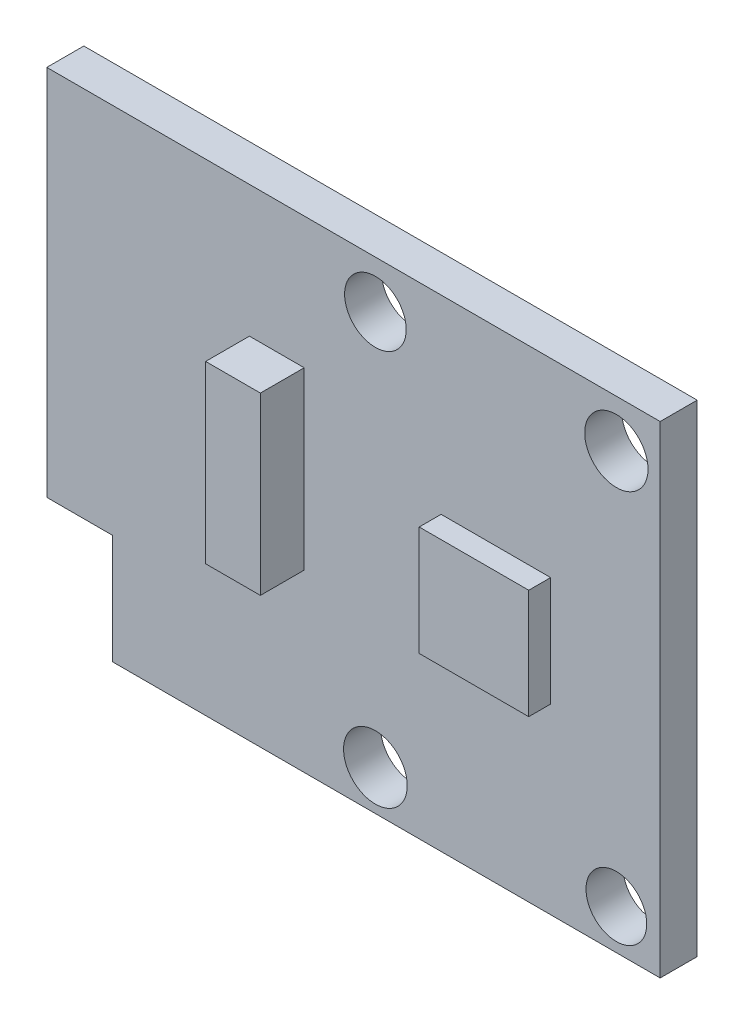
from build123d import *

# Parameters (mm, degrees)
SKETCH1_W           = 28
SKETCH1_H           = 22
BOSS_EXTRUDE1_DEPTH = 1.69
SKETCH2_R           = 1.445350302
SKETCH2_R_2         = 1.385905996
SKETCH2_R_3         = 1.453223353
SKETCH2_R_4         = 1.406338145
CUT_EXTRUDE1_DEPTH  = 1.69
SKETCH3_W           = 5
SKETCH3_H           = 5
BOSS_EXTRUDE2_DEPTH = 1
SKETCH4_W           = 2.5
SKETCH4_H           = 8
BOSS_EXTRUDE3_DEPTH = 2
SKETCH5_W           = 3
SKETCH5_H           = 5
CUT_EXTRUDE2_DEPTH  = 10


with BuildPart() as part:
    # Sketch1 → Boss-Extrude1 (new body)
    with BuildSketch(Plane.XY):
        with Locations((14, 11)):
            Rectangle(SKETCH1_W, SKETCH1_H)
    extrude(amount=BOSS_EXTRUDE1_DEPTH)

    # Sketch2 → Cut-Extrude1 (cut)
    with BuildSketch(Plane.XY.offset(1.69)):
        with Locations((26, 19.834515058)):
            Circle(SKETCH2_R)
        with Locations((26, 1.826288901)):
            Circle(SKETCH2_R_2)
        with Locations((15, 1.826288901)):
            Circle(SKETCH2_R_3)
        with Locations((15, 19.834515058)):
            Circle(SKETCH2_R_4)
    extrude(amount=-CUT_EXTRUDE1_DEPTH, mode=Mode.SUBTRACT)

    # Sketch3 → Boss-Extrude2 (add)
    with BuildSketch(Plane.XY.offset(1.69)):
        with Locations((20.5, 10.83040198)):
            Rectangle(SKETCH3_W, SKETCH3_H)
    extrude(amount=BOSS_EXTRUDE2_DEPTH)

    # Sketch4 → Boss-Extrude3 (add)
    with BuildSketch(Plane.XY.offset(1.69)):
        with Locations((10.5, 12)):
            Rectangle(SKETCH4_W, SKETCH4_H)
    extrude(amount=BOSS_EXTRUDE3_DEPTH)

    # Sketch5 → Cut-Extrude2 (cut)
    with BuildSketch(Plane.XY.offset(1.69)):
        with Locations((1.5, 2.5)):
            Rectangle(SKETCH5_W, SKETCH5_H)
    extrude(amount=-CUT_EXTRUDE2_DEPTH, mode=Mode.SUBTRACT)


solid = part.part
